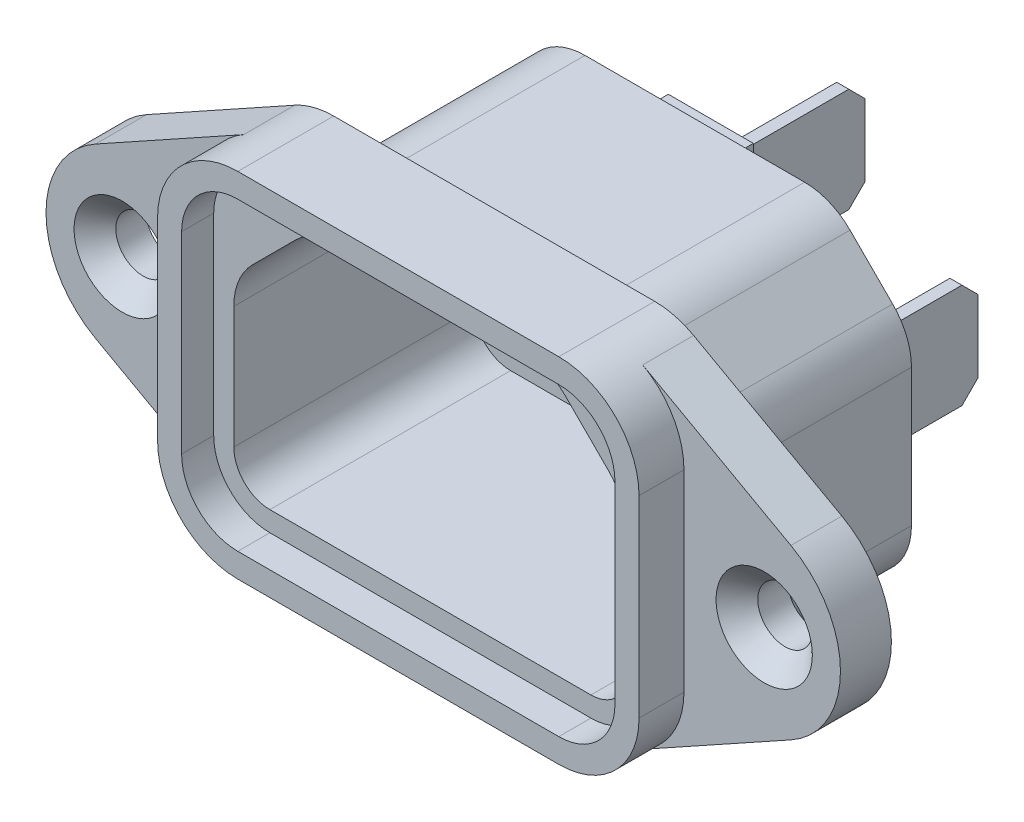
from build123d import *

# Parameters (mm, degrees)
SKETCH1_W            = 49.5
SKETCH1_H            = 22
BOSS_EXTRUDE1_DEPTH  = 3.175
SKETCH2_W            = 30
SKETCH2_H            = 22
BOSS_EXTRUDE2_DEPTH  = 2.8
FILLET1_R            = 5
SKETCH4_W            = 27
SKETCH4_H            = 19.2
BOSS_EXTRUDE3_DEPTH  = 12.5
CHAMFER1_SIZE        = 5
FILLET2_R            = 4
SKETCH3_R            = 1.7
CUT_EXTRUDE1_DEPTH   = 16.675
CUT_EXTRUDE2_DEPTH   = 16.2
MIRROR2_COPY_1_DEPTH = 16.2
CHAMFER2_SIZE        = 1.3
CUT_EXTRUDE4_DEPTH   = 17
FILLET3_R            = 4
SKETCH9_W            = 5.3
SKETCH9_H            = 11.15
BOSS_EXTRUDE4_DEPTH  = 1
SKETCH10_W           = 0.75
SKETCH10_H           = 6.5
BOSS_EXTRUDE5_DEPTH  = 9.22
CHAMFER3_SIZE        = 1
CUT_EXTRUDE3_DEPTH   = 2


with BuildPart() as part:
    # Sketch1 → Boss-Extrude1 (new body)
    with BuildSketch(Plane.XY):
        Rectangle(SKETCH1_W, SKETCH1_H)
    extrude(amount=BOSS_EXTRUDE1_DEPTH)

    # Sketch2 → Boss-Extrude2 (add)
    with BuildSketch(Plane.XY.offset(3.175)):
        Rectangle(SKETCH2_W, SKETCH2_H)
    extrude(amount=BOSS_EXTRUDE2_DEPTH)

    # Fillet1
    fillet1_edges = [part.edges().sort_by_distance(p)[0] for p in [
        (-15, 11, 4.575),
        (15, 11, 4.575),
        (15, -11, 4.575),
        (-15, -11, 4.575),
    ]]
    fillet(fillet1_edges, radius=FILLET1_R)

    # Sketch4 → Boss-Extrude3 (add)
    with BuildSketch(Plane(origin=(0, 0, 0), x_dir=(-1, 0, 0), z_dir=(0, 0, -1))):
        Rectangle(SKETCH4_W, SKETCH4_H)
    extrude(amount=BOSS_EXTRUDE3_DEPTH)

    # Chamfer1
    chamfer1_edges = [part.edges().sort_by_distance(p)[0] for p in [
        (13.5, 9.6, -6.25),
        (-13.5, 9.6, -6.25),
    ]]
    chamfer(chamfer1_edges, length=CHAMFER1_SIZE)

    # Fillet2
    fillet2_edges = [part.edges().sort_by_distance(p)[0] for p in [
        (13.5, -9.6, -6.25),
        (-13.5, -9.6, -6.25),
        (8.5, 9.6, -6.25),
        (-8.5, 9.6, -6.25),
        (-13.5, 4.6, -6.25),
        (13.5, 4.6, -6.25),
    ]]
    fillet(fillet2_edges, radius=FILLET2_R)

    # Sketch3 → Cut-Extrude1 (cut, through all)
    with BuildSketch(Plane.XY.offset(3.175)):
        with Locations((-20, 0)):
            Circle(SKETCH3_R)
        with Locations((20, 0)):
            Circle(SKETCH3_R)
    extrude(amount=-CUT_EXTRUDE1_DEPTH, mode=Mode.SUBTRACT)

    # Sketch5 → Cut-Extrude2 (cut)
    with BuildSketch(Plane.XY.offset(3.175)):
        with BuildLine():
            Line((-12.426380479, 10.371804865), (-21.661656574, 5.246165837))
            ThreePointArc((-21.661656574, 5.246165837), (-23.92058698, 3.043851225), (-24.75, 0))
            Line((-24.75, 0), (-24.75, 11))
            Line((-24.75, 11), (-10, 11))
            ThreePointArc((-10, 11), (-11.253191062, 10.840404132), (-12.426380479, 10.371804865))
        make_face()
    cut_extrude2 = extrude(amount=-CUT_EXTRUDE2_DEPTH, mode=Mode.SUBTRACT)

    # Mirror1: Cut-Extrude2 across plane
    add(cut_extrude2.mirror(Plane.ZX), mode=Mode.SUBTRACT)

    # Mirror2: Cut-Extrude2 across plane
    add(cut_extrude2.mirror(Plane(origin=(0, 0, 0), x_dir=(0, 0, 1), z_dir=(1, 0, 0))), mode=Mode.SUBTRACT)

    # Mirror2 copy 1 sketch → Mirror2 copy 1 (cut)
    with BuildSketch(Plane(origin=(0, 0, 3.175), x_dir=(-1, 0, 0), z_dir=(0, 0, 1))):
        with BuildLine():
            Line((-12.426380479, 10.371804865), (-21.661656574, 5.246165837))
            ThreePointArc((-21.661656574, 5.246165837), (-23.92058698, 3.043851225), (-24.75, 0))
            Line((-24.75, 0), (-24.75, 11))
            Line((-24.75, 11), (-10, 11))
            ThreePointArc((-10, 11), (-11.253191062, 10.840404132), (-12.426380479, 10.371804865))
        make_face()
    extrude(amount=-MIRROR2_COPY_1_DEPTH, mode=Mode.SUBTRACT)

    # Chamfer2
    chamfer2_edges = [part.edges().sort_by_distance(p)[0] for p in [
        (-21.7, 0, 3.175),
        (18.3, 0, 3.175),
    ]]
    chamfer(chamfer2_edges, length=CHAMFER2_SIZE)

    # Sketch8 → Cut-Extrude4 (cut)
    with BuildSketch(Plane.XY.offset(5.975)):
        with BuildLine():
            Line((-7.25, 8.25), (-12.25, 3.25))
            Line((-12.25, 3.25), (-12.25, -6))
            ThreePointArc((-12.25, -6), (-11.590990258, -7.590990258), (-10, -8.25))
            Line((-10, -8.25), (10, -8.25))
            ThreePointArc((10, -8.25), (11.590990258, -7.590990258), (12.25, -6))
            Line((12.25, -6), (12.25, 3.25))
            Line((12.25, 3.25), (7.25, 8.25))
            Line((7.25, 8.25), (-7.25, 8.25))
        make_face()
    extrude(amount=-CUT_EXTRUDE4_DEPTH, mode=Mode.SUBTRACT)

    # Fillet3
    fillet3_edges = [part.edges().sort_by_distance(p)[0] for p in [
        (-7.25, 8.25, -2.525),
        (7.25, 8.25, -2.525),
        (12.25, 3.25, -2.525),
        (-12.25, 3.25, -2.525),
    ]]
    fillet(fillet3_edges, radius=FILLET3_R)

    # Sketch9 → Boss-Extrude4 (add)
    with BuildSketch(Plane(origin=(0, 0, -12.5), x_dir=(-1, 0, 0), z_dir=(0, 0, -1))):
        with Locations((0, 3.525)):
            Rectangle(SKETCH9_W, SKETCH9_H)
        with Locations((-7.05, -3.525)):
            Rectangle(SKETCH9_W, SKETCH9_H)
        with Locations((7.05, -3.525)):
            Rectangle(SKETCH9_W, SKETCH9_H)
    extrude(amount=BOSS_EXTRUDE4_DEPTH)

    # Sketch10 → Boss-Extrude5 (add)
    with BuildSketch(Plane(origin=(0, 0, -13.5), x_dir=(-1, 0, 0), z_dir=(0, 0, -1))):
        with Locations((0, 3.525)):
            Rectangle(SKETCH10_W, SKETCH10_H)
        with Locations((-7.05, -3.525)):
            Rectangle(SKETCH10_W, SKETCH10_H)
        with Locations((7.05, -3.525)):
            Rectangle(SKETCH10_W, SKETCH10_H)
    extrude(amount=BOSS_EXTRUDE5_DEPTH)

    # Chamfer3
    chamfer3_edges = [part.edges().sort_by_distance(p)[0] for p in [
        (0, 0.275, -22.72),
        (0, 6.775, -22.72),
        (7.05, -6.775, -22.72),
        (7.05, -0.275, -22.72),
        (-7.05, -6.775, -22.72),
        (-7.05, -0.275, -22.72),
    ]]
    chamfer(chamfer3_edges, length=CHAMFER3_SIZE)

    # Sketch6 → Cut-Extrude3 (cut)
    with BuildSketch(Plane.XY.offset(5.975)):
        with BuildLine():
            Line((-13.5, 6), (-13.5, -6))
            ThreePointArc((-13.5, -6), (-12.474873734, -8.474873734), (-10, -9.5))
            Line((-10, -9.5), (10, -9.5))
            ThreePointArc((10, -9.5), (12.474873734, -8.474873734), (13.5, -6))
            Line((13.5, -6), (13.5, 6))
            ThreePointArc((13.5, 6), (12.474873734, 8.474873734), (10, 9.5))
            Line((10, 9.5), (-10, 9.5))
            ThreePointArc((-10, 9.5), (-12.474873734, 8.474873734), (-13.5, 6))
        make_face()
    extrude(amount=-CUT_EXTRUDE3_DEPTH, mode=Mode.SUBTRACT)


solid = part.part
